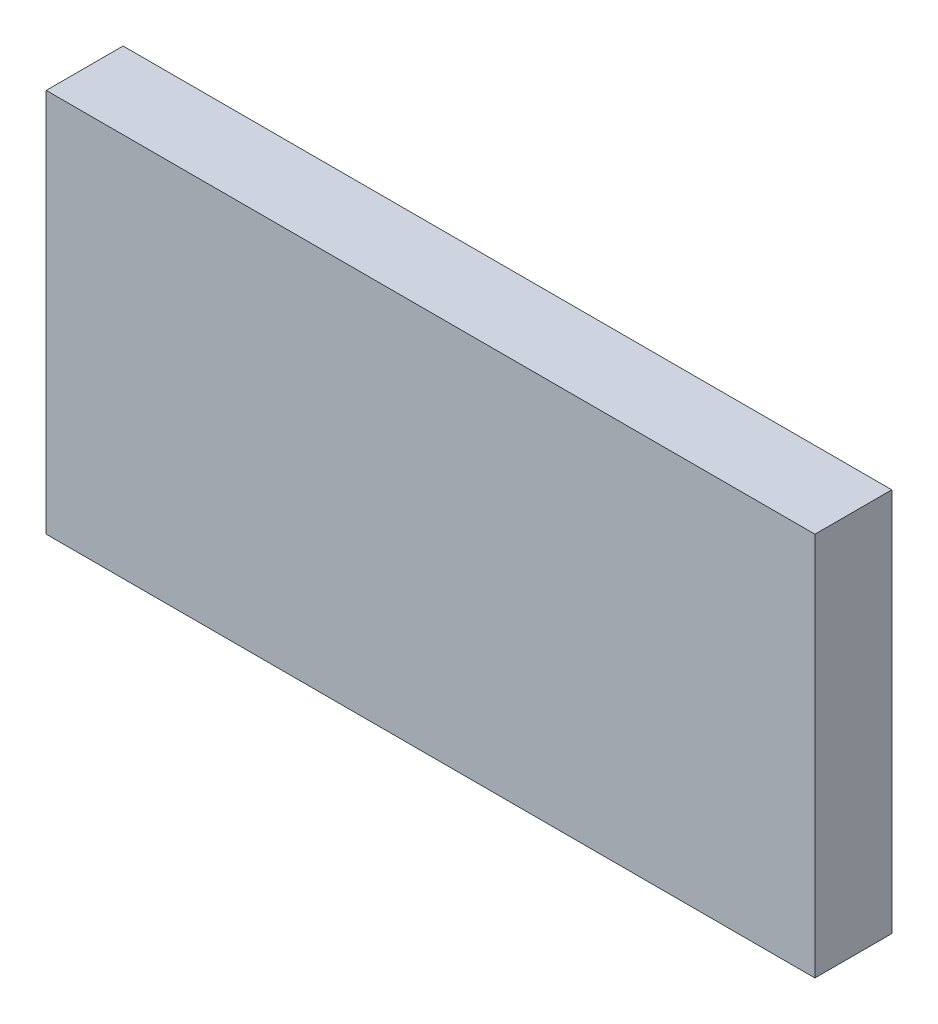
from build123d import *

# Parameters (mm, degrees)
ESQUISSE1_W        = 100
ESQUISSE1_H        = 50
BOSS_EXTRU_1_DEPTH = 10


with BuildPart() as part:
    # Esquisse1 → Boss.-Extru.1 (new body)
    with BuildSketch(Plane.XY):
        Rectangle(ESQUISSE1_W, ESQUISSE1_H)
    extrude(amount=BOSS_EXTRU_1_DEPTH)


solid = part.part
